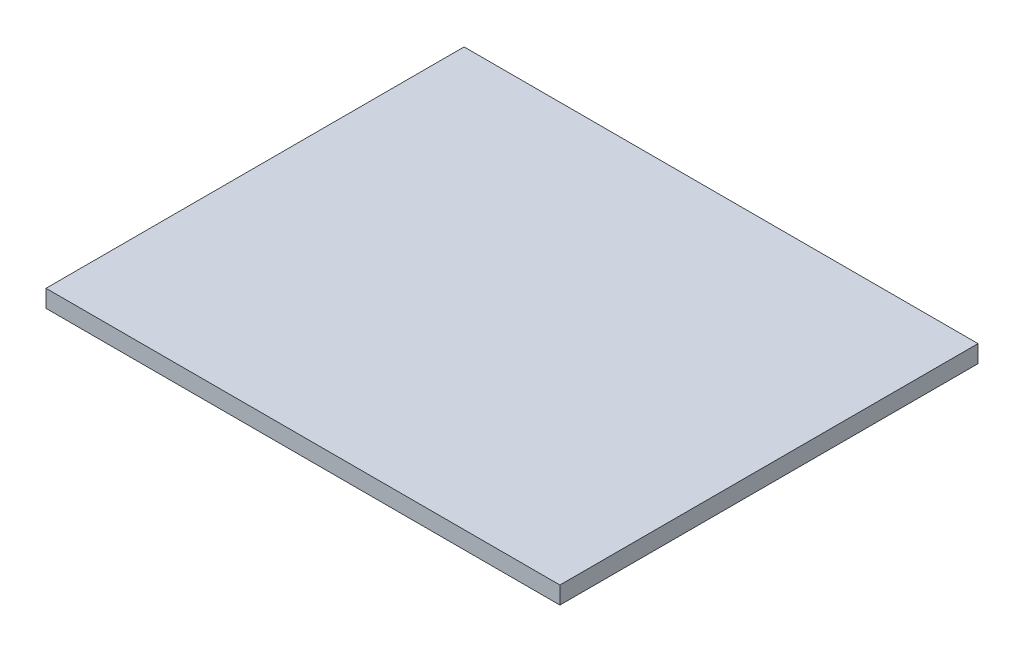
from build123d import *

# Parameters (mm, degrees)
SKETCH1_W           = 118
SKETCH1_H           = 96
BOSS_EXTRUDE1_DEPTH = 4


with BuildPart() as part:
    # Sketch1 → Boss-Extrude1 (new body)
    with BuildSketch(Plane(origin=(0, 0, 0), x_dir=(1, 0, 0), z_dir=(0, 1, 0))):
        Rectangle(SKETCH1_W, SKETCH1_H)
    extrude(amount=BOSS_EXTRUDE1_DEPTH)


solid = part.part
